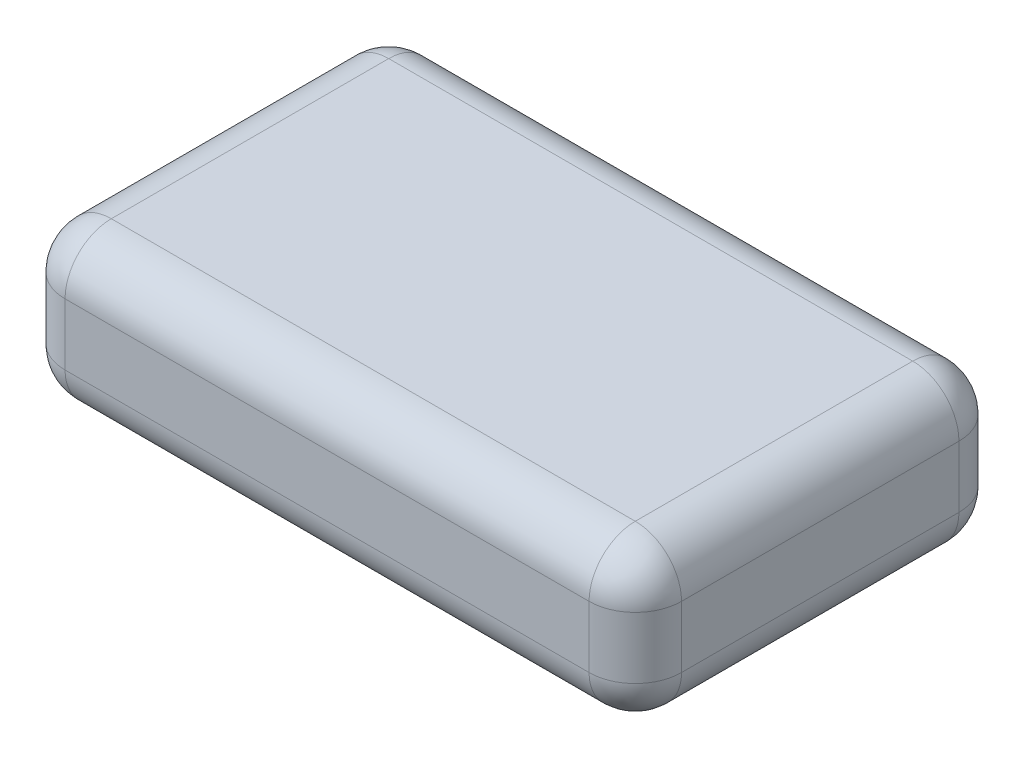
from build123d import *

# Parameters (mm, degrees)
SKETCH1_W           = 254
SKETCH1_H           = 152.4
BOSS_EXTRUDE1_DEPTH = 63.5
FILLET1_R           = 19.05


with BuildPart() as part:
    # Sketch1 → Boss-Extrude1 (new body)
    with BuildSketch(Plane(origin=(0, 0, 0), x_dir=(1, 0, 0), z_dir=(0, 1, 0))):
        Rectangle(SKETCH1_W, SKETCH1_H)
    extrude(amount=BOSS_EXTRUDE1_DEPTH)

    # Fillet1
    fillet1_edges = [part.edges().sort_by_distance(p)[0] for p in [
        (-127, 63.5, 0),
        (0, 63.5, 76.2),
        (127, 63.5, 0),
        (0, 0, 76.2),
        (-127, 0, 0),
        (0, 0, -76.2),
        (127, 0, 0),
        (127, 31.75, 76.2),
        (-127, 31.75, 76.2),
        (-127, 31.75, -76.2),
        (127, 31.75, -76.2),
        (0, 63.5, -76.2),
    ]]
    fillet(fillet1_edges, radius=FILLET1_R)


solid = part.part
